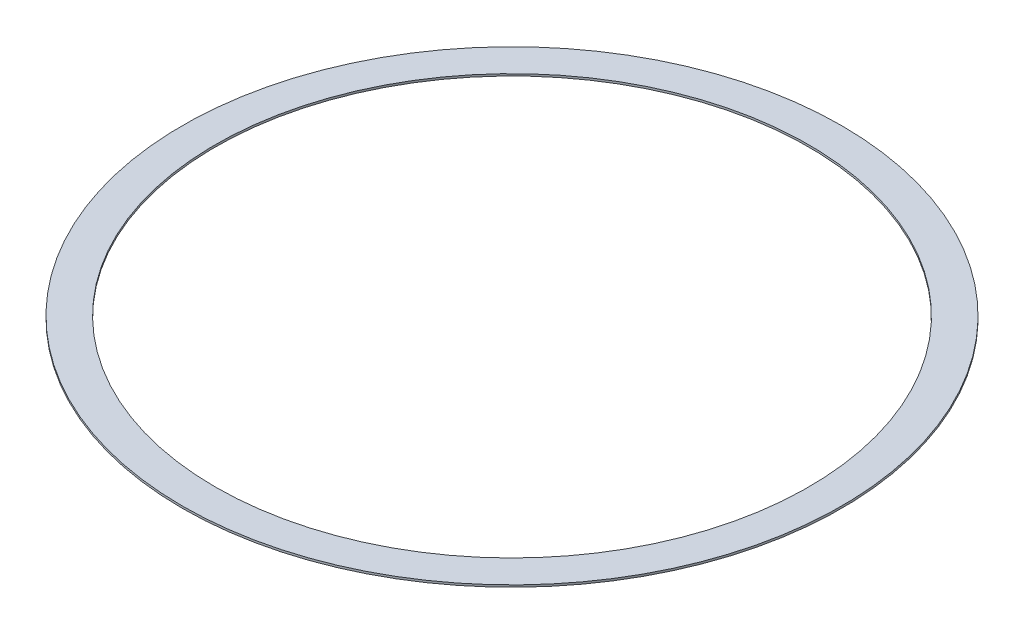
from build123d import *

# Parameters (mm, degrees)
SKETCH1_R           = 254
SKETCH1_R_2         = 228.6
BOSS_EXTRUDE1_DEPTH = 1.5875


with BuildPart() as part:
    # Sketch1 → Boss-Extrude1 (new body)
    with BuildSketch(Plane(origin=(0, 0, 0), x_dir=(1, 0, 0), z_dir=(0, 1, 0))):
        Circle(SKETCH1_R)
        Circle(SKETCH1_R_2, mode=Mode.SUBTRACT)
    extrude(amount=BOSS_EXTRUDE1_DEPTH)


solid = part.part
